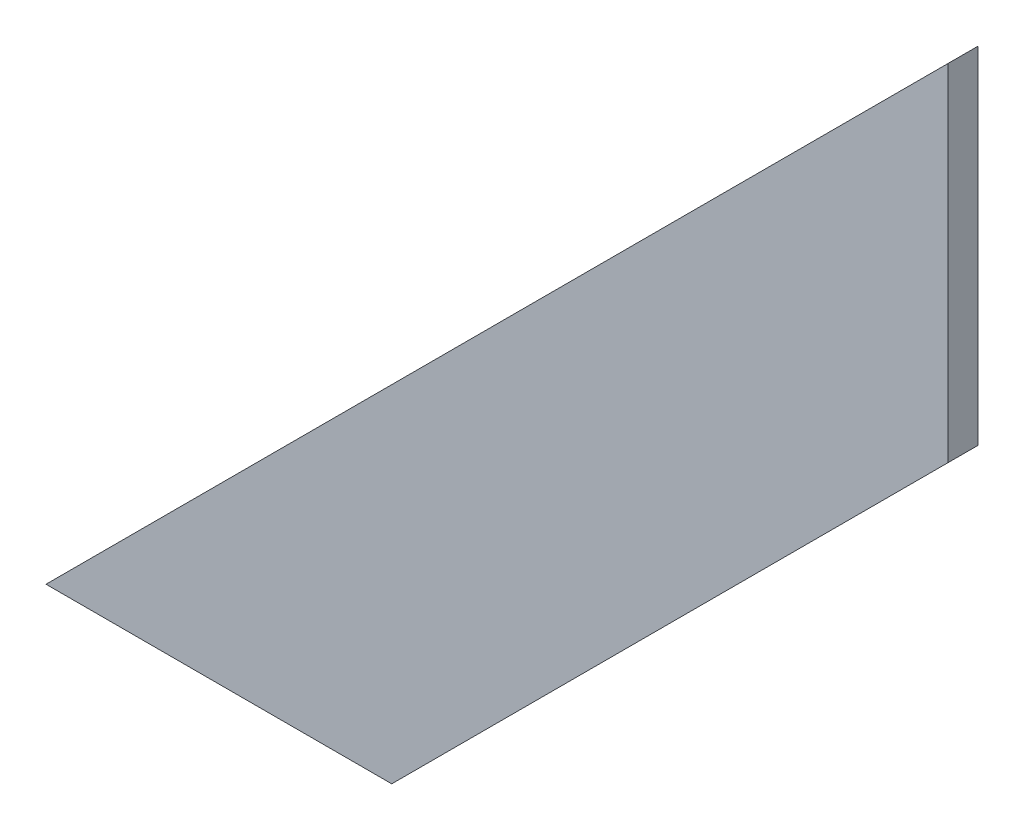
from build123d import *

# Parameters (mm, degrees)
BOSS_EXTRUDE1_DEPTH = 2


with BuildPart() as part:
    # Sketch1 → Boss-Extrude1 (new body)
    with BuildSketch(Plane.XY):
        Polygon((0, 0), (60, 60), (60, 37), (23, 0), align=None)
    extrude(amount=BOSS_EXTRUDE1_DEPTH)


solid = part.part
